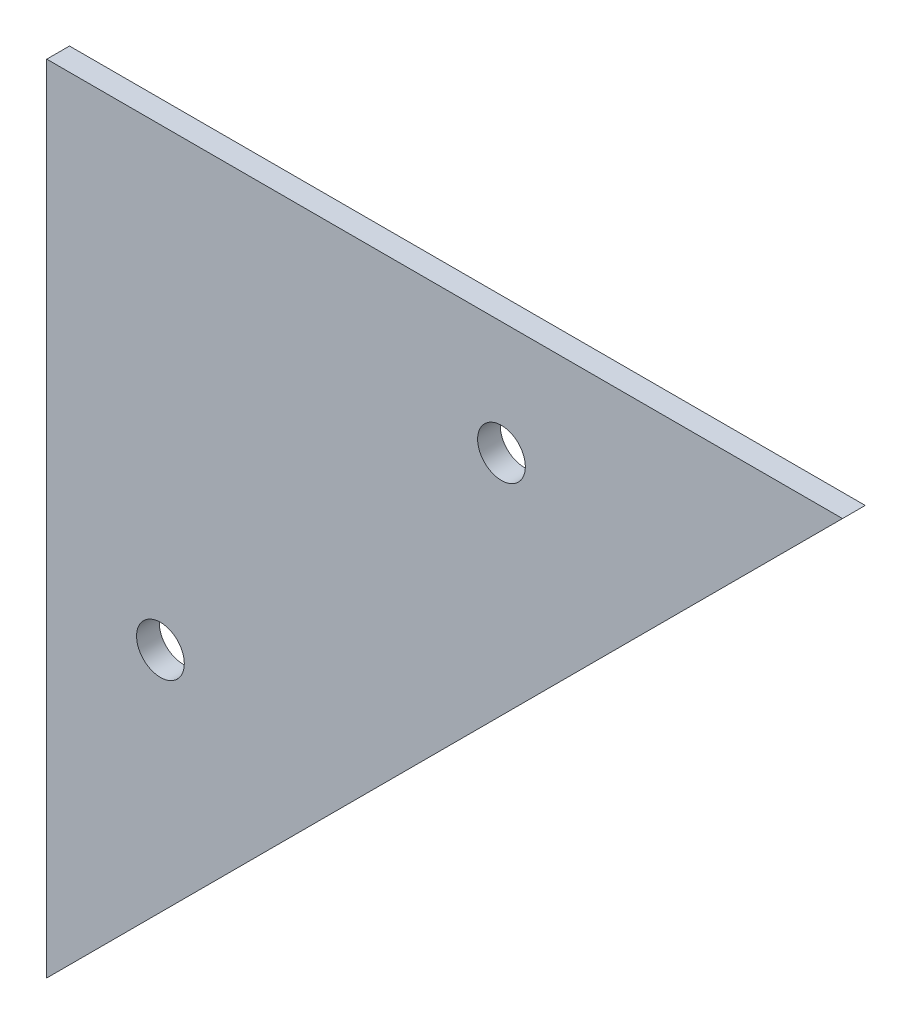
from build123d import *

# Parameters (mm, degrees)
SKETCH_1_R      = 2.1
EXTRUDE_1_DEPTH = 2


with BuildPart() as part:
    # ｽｹｯﾁ1 → ﾎﾞｽ - 押し出し1 (new body)
    with BuildSketch(Plane.XY):
        Polygon((0, 0), (0, -70), (70, 0), align=None)
        with Locations((10, -40)):
            Circle(SKETCH_1_R, mode=Mode.SUBTRACT)
        with Locations((40, -10)):
            Circle(SKETCH_1_R, mode=Mode.SUBTRACT)
    extrude(amount=EXTRUDE_1_DEPTH)


solid = part.part
